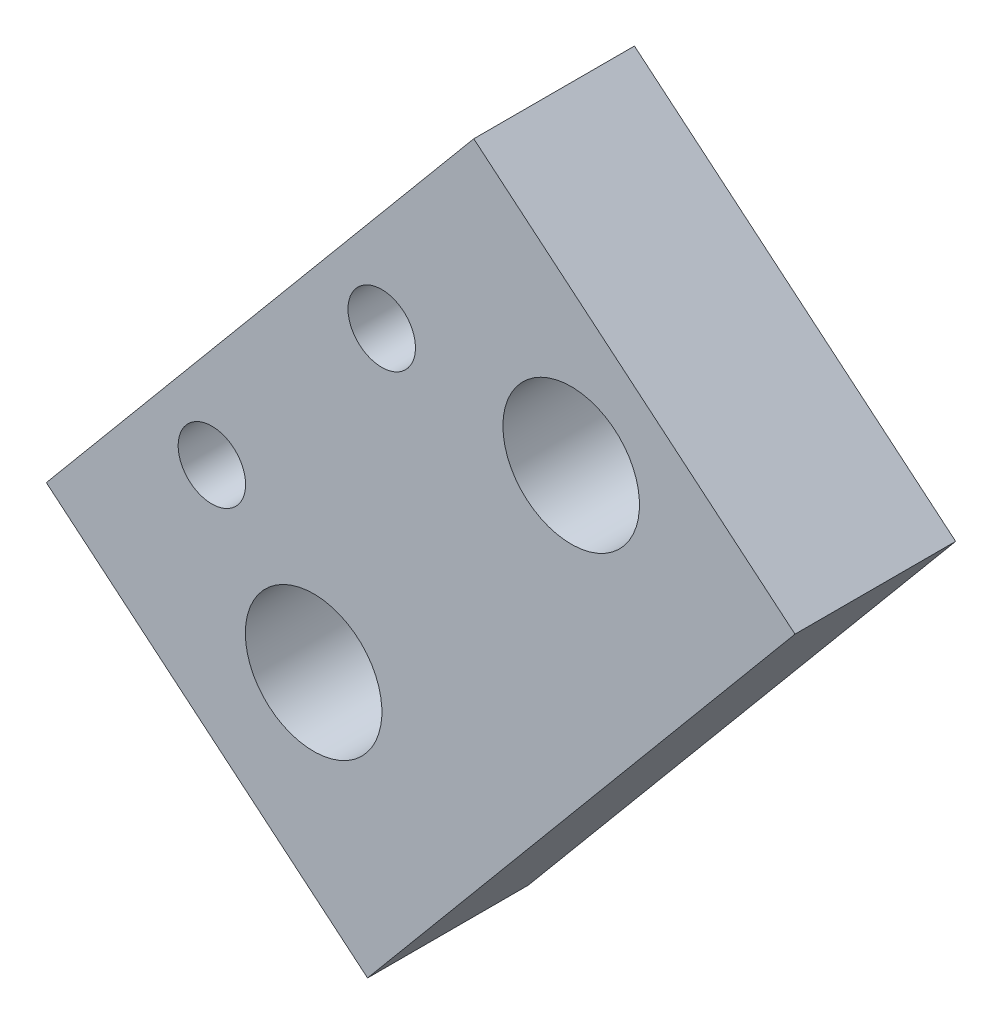
from build123d import *

# Parameters (mm, degrees)
SKETCH2_R           = 4.25
SKETCH2_R_2         = 2.1
BOSS_EXTRUDE1_DEPTH = 10


with BuildPart() as part:
    # Sketch2 → Boss-Extrude1 (new body)
    with BuildSketch(Plane(origin=(0, 0, 32430.966139434), x_dir=(-1, 0, 0), z_dir=(0, 0, -1))):
        Polygon((-107.287132076, 528.630767378), (-87.295661635, 545.336840216), (-60.692285166, 513.501673478), (-80.683755608, 496.79560064), align=None)
        with Locations((-77.326966288, 511.582577545)):
            Circle(SKETCH2_R, mode=Mode.SUBTRACT)
        with Locations((-93.357902826, 530.766140137)):
            Circle(SKETCH2_R, mode=Mode.SUBTRACT)
        with Locations((-81.566936891, 532.251222865)):
            Circle(SKETCH2_R_2, mode=Mode.SUBTRACT)
        with Locations((-70.99449696, 519.599618719)):
            Circle(SKETCH2_R_2, mode=Mode.SUBTRACT)
    extrude(amount=BOSS_EXTRUDE1_DEPTH)


solid = part.part
